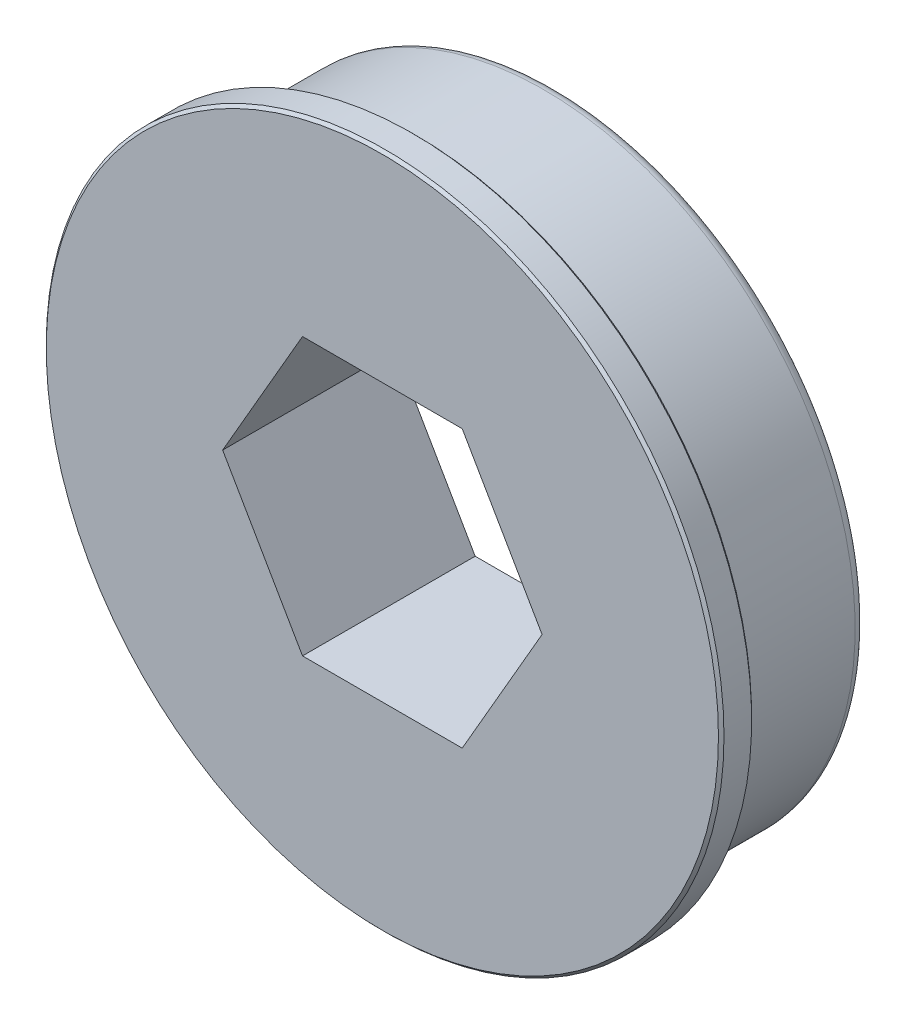
from build123d import *

# Parameters (mm, degrees)
CUT_EXTRUDE1_DEPTH = 8.92734
CHAMFER1_SIZE      = 0.127
FILLET1_R          = 0.508


with BuildPart() as part:
    # Sketch1 → Revolve1 (revolve)
    with BuildSketch(Plane.XZ):
        Polygon((15.5575, 7.92734), (0, 7.92734), (0, 0), (14.2875, 0), (14.2875, 5.89534), (13.97, 5.89534), (13.97, 6.40334), (15.5575, 6.40334), align=None)
    revolve(axis=Axis((0, 0, 7.92734), (0, 0, -1)))

    # Sketch2 → Cut-Extrude1 (cut, through all)
    with BuildSketch(Plane.XY.offset(7.92734)):
        Polygon((7.332348419, 0), (3.666174209, 6.35), (-3.666174209, 6.35), (-7.332348419, 0), (-3.666174209, -6.35), (3.666174209, -6.35), align=None)
    extrude(amount=-CUT_EXTRUDE1_DEPTH, mode=Mode.SUBTRACT)

    # Chamfer1
    chamfer1_edges = [part.edges().sort_by_distance(p)[0] for p in [
        (-15.5575, 0, 6.40334),
        (-15.5575, 0, 7.92734),
    ]]
    chamfer(chamfer1_edges, length=CHAMFER1_SIZE)

    # Fillet1
    fillet1_edges = [part.edges().sort_by_distance(p)[0] for p in [
        (-14.2875, 0, 0),
    ]]
    fillet(fillet1_edges, radius=FILLET1_R)


solid = part.part
